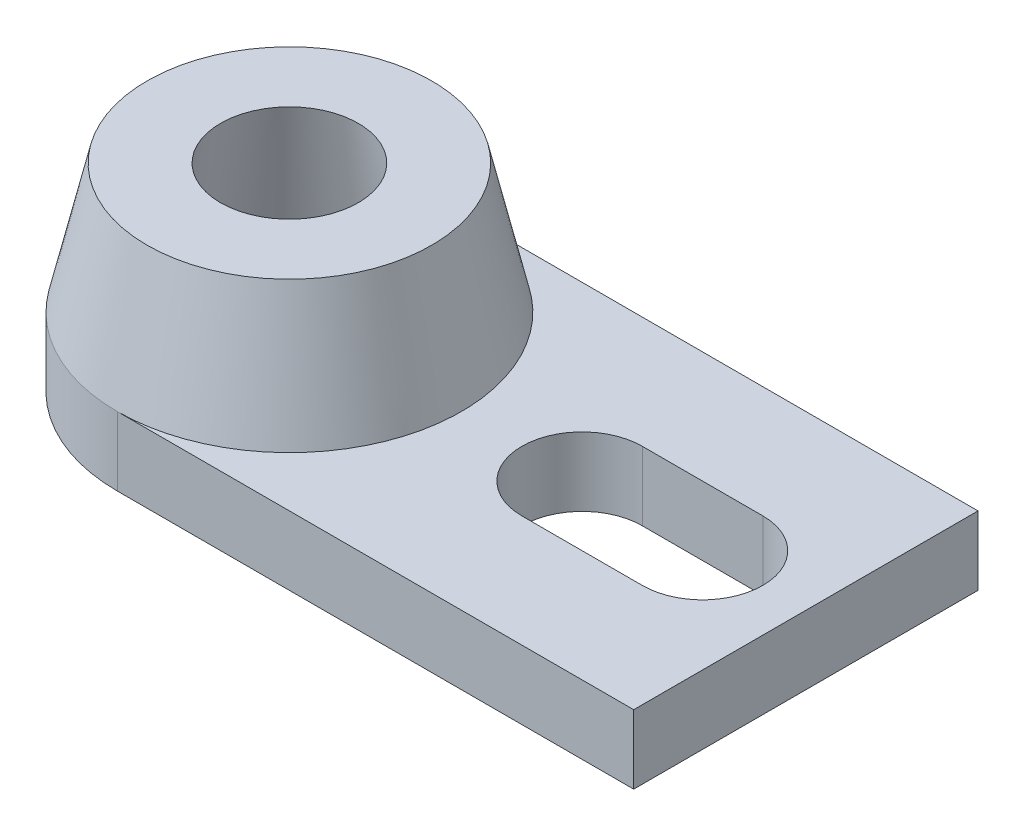
from build123d import *

# Parameters (mm, degrees)
SALIENTE_EXTRUIR1_DEPTH = 8
CROQUIS2_R              = 20
SALIENTE_EXTRUIR2_DEPTH = 15
SALIENTE_EXTRUIR2_TAPER = 13
CROQUIS4_R              = 8
CORTAR_EXTRUIR3_DEPTH   = 23
CORTAR_EXTRUIR3_TAPER   = -10


with BuildPart() as part:
    # Croquis1 → Saliente-Extruir1 (new body)
    with BuildSketch(Plane(origin=(0, 0, 0), x_dir=(1, 0, 0), z_dir=(0, 1, 0))):
        with BuildLine():
            Line((20, 0), (80, 0))
            Line((80, 0), (80, -40))
            Line((80, -40), (20, -40))
            ThreePointArc((20, -40), (0, -20), (20, 0))
        make_face()
        with BuildLine():
            Line((68, -13), (54, -13))
            ThreePointArc((54, -13), (47, -20), (54, -27))
            Line((54, -27), (68, -27))
            ThreePointArc((68, -27), (75, -20), (68, -13))
        make_face(mode=Mode.SUBTRACT)
    extrude(amount=SALIENTE_EXTRUIR1_DEPTH)

    # Croquis2 → Saliente-Extruir2 (add)
    with BuildSketch(Plane(origin=(0, 8, 0), x_dir=(1, 0, 0), z_dir=(0, 1, 0))):
        with Locations((20, -20)):
            Circle(CROQUIS2_R)
    extrude(amount=SALIENTE_EXTRUIR2_DEPTH, taper=SALIENTE_EXTRUIR2_TAPER)

    # Croquis4 → Cortar-Extruir3 (cut)
    with BuildSketch(Plane(origin=(0, 23, 0), x_dir=(1, 0, 0), z_dir=(0, 1, 0))):
        with Locations((20, -20)):
            Circle(CROQUIS4_R)
    extrude(amount=-CORTAR_EXTRUIR3_DEPTH, taper=CORTAR_EXTRUIR3_TAPER, mode=Mode.SUBTRACT)


solid = part.part
